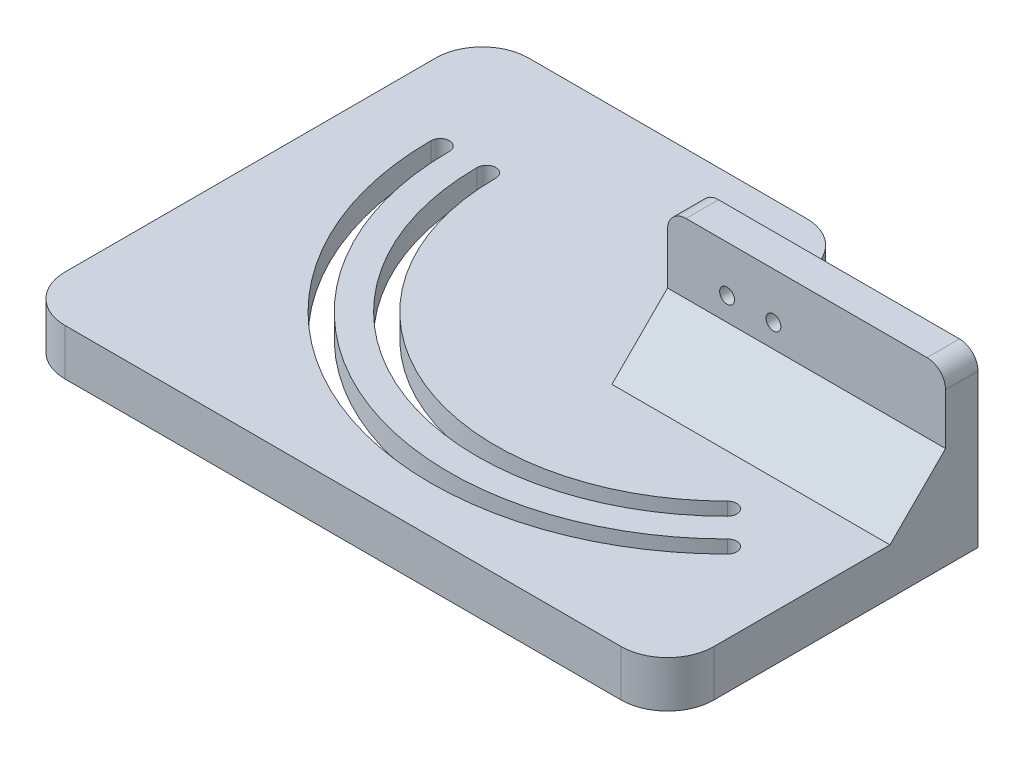
from build123d import *

# Parameters (mm, degrees)
SKETCH1_W           = 170
SKETCH1_H           = 120
BOSS_EXTRUDE1_DEPTH = 10
SKETCH2_W           = 60
SKETCH2_H           = 40
BOSS_EXTRUDE2_DEPTH = 2
SKETCH3_W           = 60
SKETCH3_H           = 8
BOSS_EXTRUDE3_DEPTH = 25
SKETCH4_R           = 1.6
CUT_EXTRUDE1_DEPTH  = 10
CUT_EXTRUDE2_DEPTH  = 36
CHAMFER1_SIZE       = 12
FILLET4_R           = 4
CHAMFER2_SIZE       = 3
CUT_EXTRUDE4_DEPTH  = 5
CUT_EXTRUDE5_DEPTH  = 19
FILLET5_R           = 10
CUT_EXTRUDE6_DEPTH  = 91
FILLET6_R           = 10


with BuildPart() as part:
    # Sketch1 → Boss-Extrude1 (new body)
    with BuildSketch(Plane(origin=(0, 0, 0), x_dir=(1, 0, 0), z_dir=(0, 1, 0))):
        with Locations((85, 60)):
            Rectangle(SKETCH1_W, SKETCH1_H)
    extrude(amount=BOSS_EXTRUDE1_DEPTH)

    # Sketch2 → Boss-Extrude2 (add)
    with BuildSketch(Plane(origin=(0, 10, 0), x_dir=(1, 0, 0), z_dir=(0, 1, 0))):
        with Locations((140, 100)):
            Rectangle(SKETCH2_W, SKETCH2_H)
    extrude(amount=BOSS_EXTRUDE2_DEPTH)

    # Sketch3 → Boss-Extrude3 (add)
    with BuildSketch(Plane(origin=(0, 12, 0), x_dir=(1, 0, 0), z_dir=(0, 1, 0))):
        with Locations((140, 84)):
            Rectangle(SKETCH3_W, SKETCH3_H)
    extrude(amount=BOSS_EXTRUDE3_DEPTH)

    # Sketch4 → Cut-Extrude1 (cut)
    with BuildSketch(Plane(origin=(0, 0, -88), x_dir=(-1, 0, 0), z_dir=(0, 0, -1))):
        with Locations((-132.854949503, 27)):
            Circle(SKETCH4_R)
        with Locations((-122.854949503, 27)):
            Circle(SKETCH4_R)
    extrude(amount=-CUT_EXTRUDE1_DEPTH, mode=Mode.SUBTRACT)

    # Sketch5 → Cut-Extrude2 (cut)
    with BuildSketch(Plane(origin=(0, 10, 0), x_dir=(1, 0, 0), z_dir=(0, 1, 0))):
        with BuildLine():
            ThreePointArc((44.934842869, 94), (84.443103198, 34.871709919), (154.189676865, 48.745166004))
            ThreePointArc((154.189676865, 48.745166004), (154.189676865, 51.573593129), (151.361249741, 51.573593129))
            ThreePointArc((151.361249741, 51.573593129), (85.973836928, 38.567228049), (48.934842869, 94))
            ThreePointArc((48.934842869, 94), (46.934842869, 96), (44.934842869, 94))
        make_face()
        with BuildLine():
            ThreePointArc((58.934842869, 94), (89.800671251, 47.806023374), (144.290181929, 58.644660941))
            ThreePointArc((144.290181929, 58.644660941), (147.118609054, 58.644660941), (147.118609054, 55.816233816))
            ThreePointArc((147.118609054, 55.816233816), (88.269937522, 44.110505244), (54.934842869, 94))
            ThreePointArc((54.934842869, 94), (56.934842869, 96), (58.934842869, 94))
        make_face()
    extrude(amount=-CUT_EXTRUDE2_DEPTH, mode=Mode.SUBTRACT)

    # Chamfer1
    chamfer1_edges = [part.edges().sort_by_distance(p)[0] for p in [
        (140, 10, -80),
    ]]
    chamfer(chamfer1_edges, length=CHAMFER1_SIZE)

    # Fillet4
    fillet4_edges = [part.edges().sort_by_distance(p)[0] for p in [
        (170, 37, -84),
        (110, 37, -84),
    ]]
    fillet(fillet4_edges, radius=FILLET4_R)

    # Chamfer2
    chamfer2_edges = [part.edges().sort_by_distance(p)[0] for p in [
        (140, 12, -88),
    ]]
    chamfer(chamfer2_edges, length=CHAMFER2_SIZE)

    # Sketch7 → Cut-Extrude4 (cut)
    with BuildSketch(Plane.XZ):
        with BuildLine():
            ThreePointArc((140.754648023, -62.180194847), (91.714088413, -52.425421037), (63.934842869, -94))
            ThreePointArc((63.934842869, -94), (51.934842869, -106), (39.934842869, -94))
            ThreePointArc((39.934842869, -94), (82.529686036, -30.252312257), (157.725210771, -45.209632098))
            ThreePointArc((157.725210771, -45.209632098), (157.725210771, -62.180194847), (140.754648023, -62.180194847))
        make_face()
    extrude(amount=-CUT_EXTRUDE4_DEPTH, mode=Mode.SUBTRACT)

    # Sketch8 → Cut-Extrude5 (cut)
    with BuildSketch(Plane(origin=(0, 10, 0), x_dir=(1, 0, 0), z_dir=(0, 1, 0))):
        Polygon((0, 0), (30, 0), (170, 0), (170, 20), (30, 20), (30, 120), (0, 120), align=None)
    extrude(amount=-CUT_EXTRUDE5_DEPTH, mode=Mode.SUBTRACT)

    # Fillet5
    fillet5_edges = [part.edges().sort_by_distance(p)[0] for p in [
        (30, 5, -120),
        (170, 5, -20),
        (110, 11, -120),
        (30, 5, -20),
        (170, 6, -120),
    ]]
    fillet(fillet5_edges, radius=FILLET5_R)

    # Sketch9 → Cut-Extrude6 (cut)
    with BuildSketch(Plane(origin=(0, 37, 0), x_dir=(1, 0, 0), z_dir=(0, 1, 0))):
        Polygon((170, 88), (170, 87), (110, 87), (110, 138.435407066), (206.694052757, 135.310318366), align=None)
    extrude(amount=-CUT_EXTRUDE6_DEPTH, mode=Mode.SUBTRACT)

    # Fillet6
    fillet6_edges = [part.edges().sort_by_distance(p)[0] for p in [
        (110, 5, -87),
        (110, 5, -120),
    ]]
    fillet(fillet6_edges, radius=FILLET6_R)


solid = part.part
